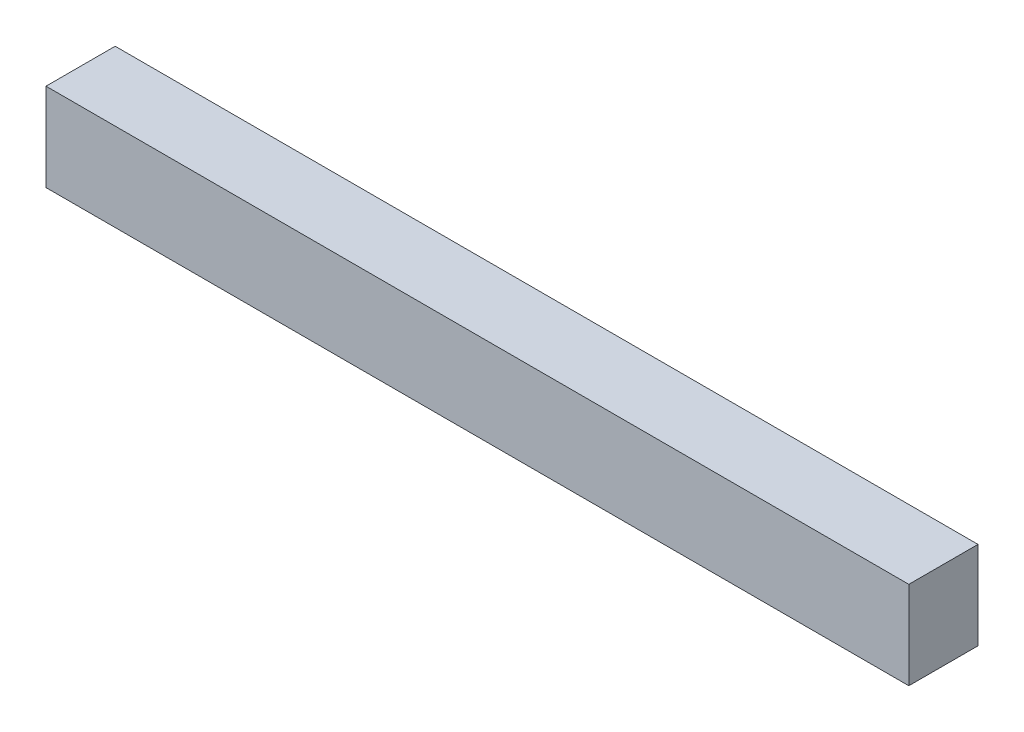
from build123d import *

# Parameters (mm, degrees)
SKETCH1_W           = 74.84
SKETCH1_H           = 6
BOSS_EXTRUDE1_DEPTH = 7.62


with BuildPart() as part:
    # Sketch1 → Boss-Extrude1 (new body)
    with BuildSketch(Plane(origin=(0, 0, 0), x_dir=(1, 0, 0), z_dir=(0, 1, 0))):
        with Locations((37.42, 3)):
            Rectangle(SKETCH1_W, SKETCH1_H)
    extrude(amount=BOSS_EXTRUDE1_DEPTH)


solid = part.part
